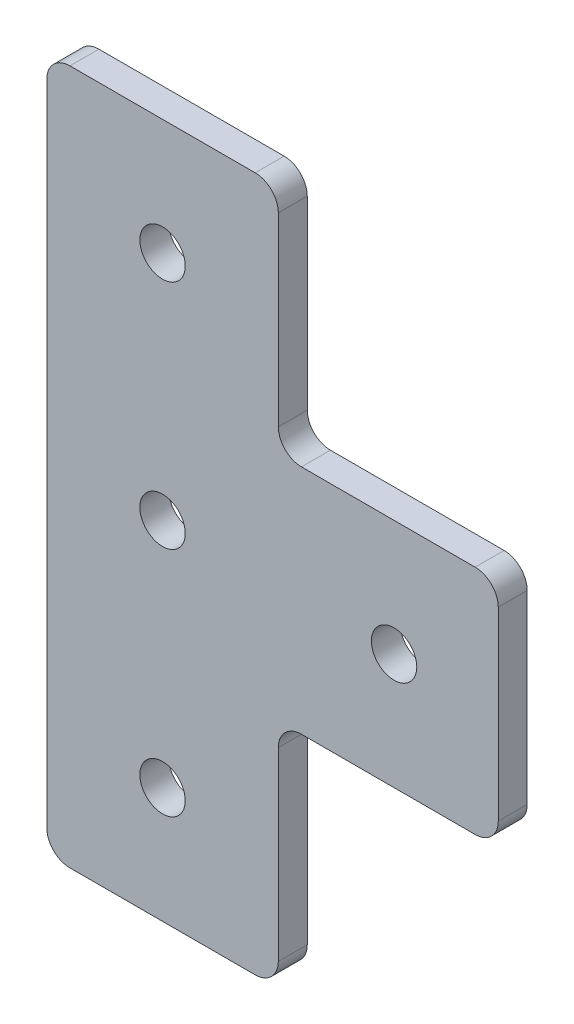
from build123d import *

# Parameters (mm, degrees)
SKETCH1_R           = 2.4892
BOSS_EXTRUDE1_DEPTH = 3.175


with BuildPart() as part:
    # Sketch1 → Boss-Extrude1 (new body)
    with BuildSketch(Plane.XY):
        with BuildLine():
            Line((-2.54, 0), (-21.59, 0))
            ThreePointArc((-21.59, 0), (-23.386051224, -0.743948776), (-24.13, -2.54))
            Line((-24.13, -2.54), (-24.13, -22.86))
            ThreePointArc((-24.13, -22.86), (-24.873948776, -24.656051224), (-26.67, -25.4))
            Line((-26.67, -25.4), (-46.99, -25.4))
            ThreePointArc((-46.99, -25.4), (-48.786051224, -24.656051224), (-49.53, -22.86))
            Line((-49.53, -22.86), (-49.53, 48.26))
            ThreePointArc((-49.53, 48.26), (-48.786051224, 50.056051224), (-46.99, 50.8))
            Line((-46.99, 50.8), (-26.67, 50.8))
            ThreePointArc((-26.67, 50.8), (-24.873948776, 50.056051224), (-24.13, 48.26))
            Line((-24.13, 48.26), (-24.13, 27.94))
            ThreePointArc((-24.13, 27.94), (-23.386051224, 26.143948776), (-21.59, 25.4))
            Line((-21.59, 25.4), (-2.54, 25.4))
            ThreePointArc((-2.54, 25.4), (-0.743948776, 24.656051224), (0, 22.86))
            Line((0, 22.86), (0, 2.54))
            ThreePointArc((0, 2.54), (-0.743948776, 0.743948776), (-2.54, 0))
        make_face()
        with Locations((-36.83, 38.1)):
            Circle(SKETCH1_R, mode=Mode.SUBTRACT)
        with Locations((-36.83, 12.7)):
            Circle(SKETCH1_R, mode=Mode.SUBTRACT)
        with Locations((-36.83, -12.7)):
            Circle(SKETCH1_R, mode=Mode.SUBTRACT)
        with Locations((-11.43, 12.7)):
            Circle(SKETCH1_R, mode=Mode.SUBTRACT)
    extrude(amount=BOSS_EXTRUDE1_DEPTH)


solid = part.part
